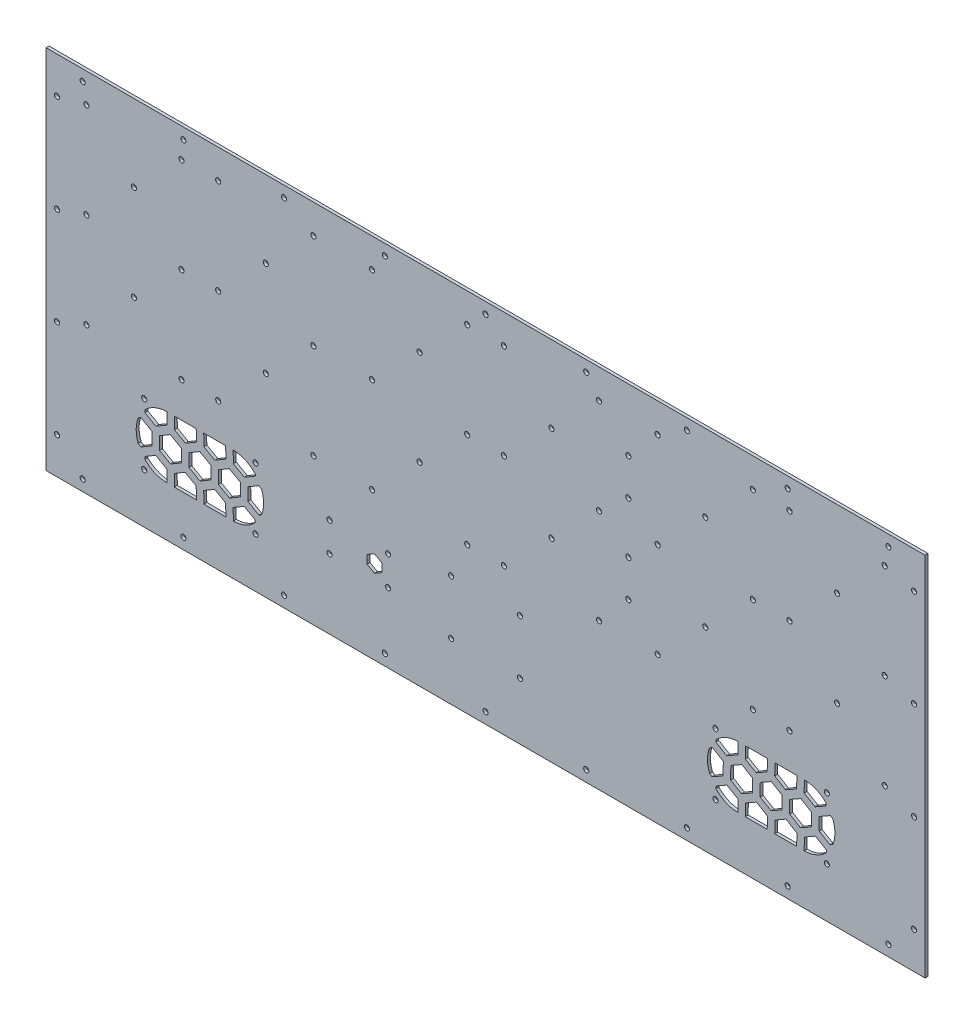
from build123d import *

# Parameters (mm, degrees)
CROQUIS2_W              = 600
CROQUIS2_H              = 250
SALIENTE_EXTRUIR1_DEPTH = 4
CROQUIS4_R              = 1.25
CROQUIS4_W              = 10
CROQUIS4_H              = 15
CORTAR_EXTRUIR4_DEPTH   = 2
CROQUIS5_R              = 1.25
CORTAR_EXTRUIR3_DEPTH   = 5
CROQUIS8_R              = 1.25
CORTAR_EXTRUIR6_DEPTH   = 5
CROQUIS11_R             = 1.25
CORTAR_EXTRUIR9_DEPTH   = 5
CORTAR_EXTRUIR7_DEPTH   = 5
CROQUIS13_R             = 1.25
CORTAR_EXTRUIR10_DEPTH  = 5
CORTAR_EXTRUIR11_DEPTH  = 2
CORTAR_EXTRUIR12_DEPTH  = 3
CROQUIS16_W             = 2
CROQUIS16_H             = 250
CORTAR_EXTRUIR13_DEPTH  = 601
CROQUIS17_R             = 1.75
CORTAR_EXTRUIR14_DEPTH  = 3


with BuildPart() as part:
    # Croquis2 → Saliente-Extruir1 (new body)
    with BuildSketch(Plane.XY):
        Rectangle(CROQUIS2_W, CROQUIS2_H)
    extrude(amount=SALIENTE_EXTRUIR1_DEPTH)

    # Croquis4 → Cortar-Extruir4 (cut)
    with BuildSketch(Plane(origin=(0, 0, 0), x_dir=(-1, 0, 0), z_dir=(0, 0, -1))):
        with Locations((-77.5, -25)):
            Circle(CROQUIS4_R)
        with Locations((-12.5, -25)):
            Circle(CROQUIS4_R)
        with Locations((-12.5, 40)):
            Circle(CROQUIS4_R)
        with Locations((-45, 7.5)):
            Circle(CROQUIS4_R)
        with Locations((-77.5, 40)):
            Circle(CROQUIS4_R)
        with Locations((-45, 72.5)):
            Circle(CROQUIS4_R)
        with Locations((-77.5, 105)):
            Circle(CROQUIS4_R)
        with Locations((-12.5, 105)):
            Circle(CROQUIS4_R)
        with Locations((12.5, -25)):
            Circle(CROQUIS4_R)
        with Locations((77.5, -25)):
            Circle(CROQUIS4_R)
        with Locations((77.5, 40)):
            Circle(CROQUIS4_R)
        with Locations((45, 7.5)):
            Circle(CROQUIS4_R)
        with Locations((12.5, 40)):
            Circle(CROQUIS4_R)
        with Locations((45, 72.5)):
            Circle(CROQUIS4_R)
        with Locations((12.5, 105)):
            Circle(CROQUIS4_R)
        with Locations((77.5, 105)):
            Circle(CROQUIS4_R)
        with Locations((117.5, -25)):
            Circle(CROQUIS4_R)
        with Locations((182.5, -25)):
            Circle(CROQUIS4_R)
        with Locations((182.5, 40)):
            Circle(CROQUIS4_R)
        with Locations((150, 7.5)):
            Circle(CROQUIS4_R)
        with Locations((117.5, 40)):
            Circle(CROQUIS4_R)
        with Locations((150, 72.5)):
            Circle(CROQUIS4_R)
        with Locations((117.5, 105)):
            Circle(CROQUIS4_R)
        with Locations((182.5, 105)):
            Circle(CROQUIS4_R)
        with Locations((-182.5, -25)):
            Circle(CROQUIS4_R)
        with Locations((-117.5, -25)):
            Circle(CROQUIS4_R)
        with Locations((-117.5, 40)):
            Circle(CROQUIS4_R)
        with Locations((-150, 7.5)):
            Circle(CROQUIS4_R)
        with Locations((-182.5, 40)):
            Circle(CROQUIS4_R)
        with Locations((-150, 72.5)):
            Circle(CROQUIS4_R)
        with Locations((-182.5, 105)):
            Circle(CROQUIS4_R)
        with Locations((-117.5, 105)):
            Circle(CROQUIS4_R)
        with Locations((207.5, -25)):
            Circle(CROQUIS4_R)
        with Locations((272.5, -25)):
            Circle(CROQUIS4_R)
        with Locations((272.5, 40)):
            Circle(CROQUIS4_R)
        with Locations((240, 7.5)):
            Circle(CROQUIS4_R)
        with Locations((207.5, 40)):
            Circle(CROQUIS4_R)
        with Locations((240, 72.5)):
            Circle(CROQUIS4_R)
        with Locations((207.5, 105)):
            Circle(CROQUIS4_R)
        with Locations((272.5, 105)):
            Circle(CROQUIS4_R)
        with Locations((-272.5, -25)):
            Circle(CROQUIS4_R)
        with Locations((-207.5, -25)):
            Circle(CROQUIS4_R)
        with Locations((-207.5, 40)):
            Circle(CROQUIS4_R)
        with Locations((-240, 7.5)):
            Circle(CROQUIS4_R)
        with Locations((-272.5, 40)):
            Circle(CROQUIS4_R)
        with Locations((-240, 72.5)):
            Circle(CROQUIS4_R)
        with Locations((-272.5, 105)):
            Circle(CROQUIS4_R)
        with Locations((-207.5, 105)):
            Circle(CROQUIS4_R)
        Polygon((221.999998415, 92.000001585), (213.999998415, 100.000001585), (221.999998415, 108.000001585), (257.999998415, 108.000001585), (265.999998415, 100.000001585), (257.999998415, 92.000001585), align=None)
        Polygon((-262, -8), (-270, -16), (-278, -8), (-278, 28), (-270, 36), (-262, 28), align=None)
        Polygon((-258.000001585, 92.000001585), (-266.000001585, 100.000001585), (-258.000001585, 108.000001585), (-222.000001585, 108.000001585), (-214.000001585, 100.000001585), (-222.000001585, 92.000001585), align=None)
        Polygon((-168.000001585, -12.000001585), (-176.000001585, -20.000001585), (-168.000001585, -28.000001585), (-132.000001585, -28.000001585), (-124.000001585, -20.000001585), (-132.000001585, -12.000001585), align=None)
        Polygon((222, 32), (214, 40), (222, 48), (258, 48), (266, 40), (258, 32), align=None)
        Polygon((-168.000001585, 92.000001585), (-176.000001585, 100.000001585), (-168.000001585, 108.000001585), (-132.000001585, 108.000001585), (-124.000001585, 100.000001585), (-132.000001585, 92.000001585), align=None)
        Polygon((221.999998415, -12.000001585), (213.999998415, -20.000001585), (221.999998415, -28.000001585), (257.999998415, -28.000001585), (265.999998415, -20.000001585), (257.999998415, -12.000001585), align=None)
        Polygon((262, -8), (270, -16), (278, -8), (278, 28), (270, 36), (262, 28), align=None)
        Polygon((218, 88), (210, 96), (202, 88), (202, 52), (210, 44), (218, 52), align=None)
        Polygon((218, -8), (210, -16), (202, -8), (202, 28), (210, 36), (218, 28), align=None)
        Polygon((-128, -8), (-120, -16), (-112, -8), (-112, 28), (-120, 36), (-128, 28), align=None)
        Polygon((-168, 32), (-176, 40), (-168, 48), (-132, 48), (-124, 40), (-132, 32), align=None)
        Polygon((-262, 88), (-270, 96), (-278, 88), (-278, 52), (-270, 44), (-262, 52), align=None)
        Polygon((262, 88), (270, 96), (278, 88), (278, 52), (270, 44), (262, 52), align=None)
        Polygon((-218, 88), (-210, 96), (-202, 88), (-202, 52), (-210, 44), (-218, 52), align=None)
        Polygon((-258, 32), (-266, 40), (-258, 48), (-222, 48), (-214, 40), (-222, 32), align=None)
        Polygon((-218, -8), (-210, -16), (-202, -8), (-202, 28), (-210, 36), (-218, 28), align=None)
        Polygon((-258.000001585, -12.000001585), (-266.000001585, -20.000001585), (-258.000001585, -28.000001585), (-222.000001585, -28.000001585), (-214.000001585, -20.000001585), (-222.000001585, -12.000001585), align=None)
        Polygon((128, 88), (120, 96), (112, 88), (112, 52), (120, 44), (128, 52), align=None)
        Polygon((131.999998415, 92.000001585), (123.999998415, 100.000001585), (131.999998415, 108.000001585), (167.999998415, 108.000001585), (175.999998415, 100.000001585), (167.999998415, 92.000001585), align=None)
        Polygon((128, -8), (120, -16), (112, -8), (112, 28), (120, 36), (128, 28), align=None)
        Polygon((131.999998415, -12.000001585), (123.999998415, -20.000001585), (131.999998415, -28.000001585), (167.999998415, -28.000001585), (175.999998415, -20.000001585), (167.999998415, -12.000001585), align=None)
        Polygon((132, 32), (124, 40), (132, 48), (168, 48), (176, 40), (168, 32), align=None)
        Polygon((172, -8), (180, -16), (188, -8), (188, 28), (180, 36), (172, 28), align=None)
        Polygon((-128, 88), (-120, 96), (-112, 88), (-112, 52), (-120, 44), (-128, 52), align=None)
        Polygon((-172, -8), (-180, -16), (-188, -8), (-188, 28), (-180, 36), (-172, 28), align=None)
        Polygon((-172, 88), (-180, 96), (-188, 88), (-188, 52), (-180, 44), (-172, 52), align=None)
        Polygon((172, 88), (180, 96), (188, 88), (188, 52), (180, 44), (172, 52), align=None)
        Polygon((-67, 88), (-75, 96), (-83, 88), (-83, 52), (-75, 44), (-67, 52), align=None)
        Polygon((-63.000001585, -12.000001585), (-71.000001585, -20.000001585), (-63.000001585, -28.000001585), (-27.000001585, -28.000001585), (-19.000001585, -20.000001585), (-27.000001585, -12.000001585), align=None)
        Polygon((-63, 32), (-71, 40), (-63, 48), (-27, 48), (-19, 40), (-27, 32), align=None)
        Polygon((-23, -8), (-15, -16), (-7, -8), (-7, 28), (-15, 36), (-23, 28), align=None)
        Polygon((23, 88), (15, 96), (7, 88), (7, 52), (15, 44), (23, 52), align=None)
        Polygon((-23, 88), (-15, 96), (-7, 88), (-7, 52), (-15, 44), (-23, 52), align=None)
        Polygon((-63.000001585, 92.000001585), (-71.000001585, 100.000001585), (-63.000001585, 108.000001585), (-27.000001585, 108.000001585), (-19.000001585, 100.000001585), (-27.000001585, 92.000001585), align=None)
        Polygon((67, 88), (75, 96), (83, 88), (83, 52), (75, 44), (67, 52), align=None)
        Polygon((23, -8), (15, -16), (7, -8), (7, 28), (15, 36), (23, 28), align=None)
        Polygon((-67, -8), (-75, -16), (-83, -8), (-83, 28), (-75, 36), (-67, 28), align=None)
        Polygon((26.999998415, 92.000001585), (18.999998415, 100.000001585), (26.999998415, 108.000001585), (62.999998415, 108.000001585), (70.999998415, 100.000001585), (62.999998415, 92.000001585), align=None)
        Polygon((27, 32), (19, 40), (27, 48), (63, 48), (71, 40), (63, 32), align=None)
        Polygon((67, -8), (75, -16), (83, -8), (83, 28), (75, 36), (67, 28), align=None)
        Polygon((26.999998415, -12.000001585), (18.999998415, -20.000001585), (26.999998415, -28.000001585), (62.999998415, -28.000001585), (70.999998415, -20.000001585), (62.999998415, -12.000001585), align=None)
        with Locations((-97.5, 10)):
            Rectangle(CROQUIS4_W, CROQUIS4_H)
        with Locations((-97.5, 70)):
            Rectangle(CROQUIS4_W, CROQUIS4_H)
    extrude(amount=-CORTAR_EXTRUIR4_DEPTH, mode=Mode.SUBTRACT)

    # Croquis5 → Cortar-Extruir3 (cut, through all)
    with BuildSketch(Plane.XY):
        with Locations((-292.5, 100)):
            Circle(CROQUIS5_R)
        with Locations((-292.5, -100)):
            Circle(CROQUIS5_R)
        with Locations((-292.5, 33.333333333)):
            Circle(CROQUIS5_R)
        with Locations((-292.5, -33.333333333)):
            Circle(CROQUIS5_R)
        with Locations((292.5, -33.333333333)):
            Circle(CROQUIS5_R)
        with Locations((292.5, 33.333333333)):
            Circle(CROQUIS5_R)
        with Locations((292.5, -100)):
            Circle(CROQUIS5_R)
        with Locations((292.5, 100)):
            Circle(CROQUIS5_R)
        with Locations((-275, 117.5)):
            Circle(CROQUIS5_R)
        with Locations((-206.25, 117.5)):
            Circle(CROQUIS5_R)
        with Locations((-137.5, 117.5)):
            Circle(CROQUIS5_R)
        with Locations((-68.75, 117.5)):
            Circle(CROQUIS5_R)
        with Locations((68.75, 117.5)):
            Circle(CROQUIS5_R)
        with Locations((137.5, 117.5)):
            Circle(CROQUIS5_R)
        with Locations((206.25, 117.5)):
            Circle(CROQUIS5_R)
        with Locations((275, 117.5)):
            Circle(CROQUIS5_R)
        with Locations((0, 117.5)):
            Circle(CROQUIS5_R)
        with Locations((0, -117.5)):
            Circle(CROQUIS5_R)
        with Locations((275, -117.5)):
            Circle(CROQUIS5_R)
        with Locations((206.25, -117.5)):
            Circle(CROQUIS5_R)
        with Locations((137.5, -117.5)):
            Circle(CROQUIS5_R)
        with Locations((68.75, -117.5)):
            Circle(CROQUIS5_R)
        with Locations((-68.75, -117.5)):
            Circle(CROQUIS5_R)
        with Locations((-137.5, -117.5)):
            Circle(CROQUIS5_R)
        with Locations((-206.25, -117.5)):
            Circle(CROQUIS5_R)
        with Locations((-275, -117.5)):
            Circle(CROQUIS5_R)
        with Locations((-77.5, -25)):
            Circle(CROQUIS5_R)
        with Locations((-12.5, -25)):
            Circle(CROQUIS5_R)
        with Locations((-12.5, 40)):
            Circle(CROQUIS5_R)
        with Locations((-45, 7.5)):
            Circle(CROQUIS5_R)
        with Locations((-77.5, 40)):
            Circle(CROQUIS5_R)
        with Locations((-45, 72.5)):
            Circle(CROQUIS5_R)
        with Locations((-77.5, 105)):
            Circle(CROQUIS5_R)
        with Locations((-12.5, 105)):
            Circle(CROQUIS5_R)
        with Locations((12.5, -25)):
            Circle(CROQUIS5_R)
        with Locations((77.5, -25)):
            Circle(CROQUIS5_R)
        with Locations((77.5, 40)):
            Circle(CROQUIS5_R)
        with Locations((45, 7.5)):
            Circle(CROQUIS5_R)
        with Locations((12.5, 40)):
            Circle(CROQUIS5_R)
        with Locations((45, 72.5)):
            Circle(CROQUIS5_R)
        with Locations((12.5, 105)):
            Circle(CROQUIS5_R)
        with Locations((77.5, 105)):
            Circle(CROQUIS5_R)
        with Locations((117.5, -25)):
            Circle(CROQUIS5_R)
        with Locations((182.5, -25)):
            Circle(CROQUIS5_R)
        with Locations((182.5, 40)):
            Circle(CROQUIS5_R)
        with Locations((150, 7.5)):
            Circle(CROQUIS5_R)
        with Locations((117.5, 40)):
            Circle(CROQUIS5_R)
        with Locations((150, 72.5)):
            Circle(CROQUIS5_R)
        with Locations((117.5, 105)):
            Circle(CROQUIS5_R)
        with Locations((182.5, 105)):
            Circle(CROQUIS5_R)
        with Locations((-182.5, -25)):
            Circle(CROQUIS5_R)
        with Locations((-117.5, -25)):
            Circle(CROQUIS5_R)
        with Locations((-117.5, 40)):
            Circle(CROQUIS5_R)
        with Locations((-150, 7.5)):
            Circle(CROQUIS5_R)
        with Locations((-182.5, 40)):
            Circle(CROQUIS5_R)
        with Locations((-150, 72.5)):
            Circle(CROQUIS5_R)
        with Locations((-182.5, 105)):
            Circle(CROQUIS5_R)
        with Locations((-117.5, 105)):
            Circle(CROQUIS5_R)
        with Locations((207.5, -25)):
            Circle(CROQUIS5_R)
        with Locations((272.5, -25)):
            Circle(CROQUIS5_R)
        with Locations((272.5, 40)):
            Circle(CROQUIS5_R)
        with Locations((240, 7.5)):
            Circle(CROQUIS5_R)
        with Locations((207.5, 40)):
            Circle(CROQUIS5_R)
        with Locations((240, 72.5)):
            Circle(CROQUIS5_R)
        with Locations((207.5, 105)):
            Circle(CROQUIS5_R)
        with Locations((272.5, 105)):
            Circle(CROQUIS5_R)
        with Locations((-272.5, -25)):
            Circle(CROQUIS5_R)
        with Locations((-207.5, -25)):
            Circle(CROQUIS5_R)
        with Locations((-207.5, 40)):
            Circle(CROQUIS5_R)
        with Locations((-240, 7.5)):
            Circle(CROQUIS5_R)
        with Locations((-272.5, 40)):
            Circle(CROQUIS5_R)
        with Locations((-240, 72.5)):
            Circle(CROQUIS5_R)
        with Locations((-272.5, 105)):
            Circle(CROQUIS5_R)
        with Locations((-207.5, 105)):
            Circle(CROQUIS5_R)
        with Locations((97.5, 22.5)):
            Circle(CROQUIS5_R)
        with Locations((97.5, -2.5)):
            Circle(CROQUIS5_R)
        with Locations((97.5, 57.5)):
            Circle(CROQUIS5_R)
        with Locations((97.5, 82.5)):
            Circle(CROQUIS5_R)
    extrude(amount=CORTAR_EXTRUIR3_DEPTH, mode=Mode.SUBTRACT)

    # Croquis8 → Cortar-Extruir6 (cut, through all)
    with BuildSketch(Plane.XY.offset(4)):
        with Locations((-233, -49)):
            Circle(CROQUIS8_R)
        with Locations((-233, -91)):
            Circle(CROQUIS8_R)
        with Locations((-157, -91)):
            Circle(CROQUIS8_R)
        with Locations((-157, -49)):
            Circle(CROQUIS8_R)
        with Locations((157, -49)):
            Circle(CROQUIS8_R)
        with Locations((157, -91)):
            Circle(CROQUIS8_R)
        with Locations((233, -91)):
            Circle(CROQUIS8_R)
        with Locations((233, -49)):
            Circle(CROQUIS8_R)
    extrude(amount=-CORTAR_EXTRUIR6_DEPTH, mode=Mode.SUBTRACT)

    # Croquis11 → Cortar-Extruir9 (cut, through all)
    with BuildSketch(Plane(origin=(0, 0, 0), x_dir=(-1, 0, 0), z_dir=(0, 0, -1))):
        with Locations((-23.5, -49)):
            Circle(CROQUIS11_R)
        with Locations((23.5, -49)):
            Circle(CROQUIS11_R)
        with Locations((23.5, -86)):
            Circle(CROQUIS11_R)
        with Locations((-23.5, -86)):
            Circle(CROQUIS11_R)
    extrude(amount=-CORTAR_EXTRUIR9_DEPTH, mode=Mode.SUBTRACT)

    # Croquis9 → Cortar-Extruir7 (cut, through all)
    with BuildSketch(Plane.XY.offset(4)):
        Polygon((207.660336161, -65.60072068), (215.200047582, -61.340116065), (222.659695125, -65.739395385), (222.579631247, -74.39927932), (215.039919826, -78.659883935), (207.580272283, -74.260604615), align=None)
        with BuildLine():
            Line((232.539914551, -57.026597388), (232.555325078, -55.359761149))
            ThreePointArc((232.555325078, -55.359761149), (225.723977048, -50.677322197), (217.613479558, -49.000306719))
            Line((217.613479558, -49.000306719), (217.540555588, -56.887922683))
            Line((217.540555588, -56.887922683), (225.00020313, -61.287202004))
            Line((225.00020313, -61.287202004), (232.539914551, -57.026597388))
        make_face()
        Polygon((212.419939167, -57.026597388), (212.494148073, -49), (197.49350701, -49), (197.420580203, -56.887922683), (204.880227746, -61.287202004), align=None)
        Polygon((192.299963782, -57.026597388), (192.374172689, -49), (177.373531625, -49), (177.300604818, -56.887922683), (184.760252361, -61.287202004), align=None)
        with BuildLine():
            ThreePointArc((172.254184004, -49.001438522), (164.047678268, -50.77609326), (157.192316823, -55.623789135))
            Line((157.192316823, -55.623789135), (157.180629434, -56.887922683))
            Line((157.180629434, -56.887922683), (164.640276977, -61.287202004))
            Line((164.640276977, -61.287202004), (172.179988398, -57.026597388))
            Line((172.179988398, -57.026597388), (172.254184004, -49.001438522))
        make_face()
        with BuildLine():
            ThreePointArc((152.911967347, -62.42967976), (151.500005641, -70.03262348), (152.935582835, -77.631143545))
            Line((152.935582835, -77.631143545), (154.679968714, -78.659883935))
            Line((154.679968714, -78.659883935), (162.219680135, -74.39927932))
            Line((162.219680135, -74.39927932), (162.299744014, -65.739395385))
            Line((162.299744014, -65.739395385), (154.840096471, -61.340116065))
            Line((154.840096471, -61.340116065), (152.911967347, -62.42967976))
        make_face()
        with BuildLine():
            ThreePointArc((157.24585479, -84.433005747), (164.052101947, -89.225851121), (172.185803255, -90.997649697))
            Line((172.185803255, -90.997649697), (172.260052276, -82.966713452))
            Line((172.260052276, -82.966713452), (164.800404733, -78.567434132))
            Line((164.800404733, -78.567434132), (157.260693312, -82.828038748))
            Line((157.260693312, -82.828038748), (157.24585479, -84.433005747))
        make_face()
        Polygon((167.420368753, -65.60072068), (174.960080174, -61.340116065), (182.419727717, -65.739395385), (182.339663839, -74.39927932), (174.799952418, -78.659883935), (167.340304875, -74.260604615), align=None)
        Polygon((177.305115847, -91), (192.30575691, -91), (192.38002766, -82.966713452), (184.920380118, -78.567434132), (177.380668697, -82.828038748), align=None)
        Polygon((187.540352457, -65.60072068), (195.080063878, -61.340116065), (202.539711421, -65.739395385), (202.459647543, -74.39927932), (194.919936122, -78.659883935), (187.460288579, -74.260604615), align=None)
        Polygon((197.425091231, -91), (212.425732295, -91), (212.500003045, -82.966713452), (205.040355502, -78.567434132), (197.500644081, -82.828038748), align=None)
        with BuildLine():
            Line((217.620619466, -82.828038748), (217.545067063, -90.9999516))
            ThreePointArc((217.545067063, -90.9999516), (225.725328044, -89.322102746), (232.604979759, -84.589002412))
            Line((232.604979759, -84.589002412), (232.61997843, -82.966713452))
            Line((232.61997843, -82.966713452), (225.160330887, -78.567434132))
            Line((225.160330887, -78.567434132), (217.620619466, -82.828038748))
        make_face()
        with BuildLine():
            Line((235.159903529, -78.659883935), (237.087982246, -77.570348724))
            ThreePointArc((237.087982246, -77.570348724), (238.499954959, -69.967375593), (237.064365996, -62.368826278))
            Line((237.064365996, -62.368826278), (235.320031286, -61.340116065))
            Line((235.320031286, -61.340116065), (227.780319865, -65.60072068))
            Line((227.780319865, -65.60072068), (227.700255986, -74.260604615))
            Line((227.700255986, -74.260604615), (235.159903529, -78.659883935))
        make_face()
        Polygon((-212.500003045, -82.966713452), (-212.425732295, -91), (-197.425091231, -91), (-197.500644081, -82.828038748), (-205.040355502, -78.567434132), align=None)
        Polygon((-192.38002766, -82.966713452), (-192.30575691, -91), (-177.305115847, -91), (-177.380668697, -82.828038748), (-184.920380118, -78.567434132), align=None)
        with BuildLine():
            ThreePointArc((-172.185803255, -90.997649697), (-164.052101947, -89.225851121), (-157.24585479, -84.433005747))
            Line((-157.24585479, -84.433005747), (-157.260693312, -82.828038748))
            Line((-157.260693312, -82.828038748), (-164.800404733, -78.567434132))
            Line((-164.800404733, -78.567434132), (-172.260052276, -82.966713452))
            Line((-172.260052276, -82.966713452), (-172.185803255, -90.997649697))
        make_face()
        with BuildLine():
            ThreePointArc((-152.935582835, -77.631143545), (-151.500005641, -70.03262348), (-152.911967347, -62.42967976))
            Line((-152.911967347, -62.42967976), (-154.840096471, -61.340116065))
            Line((-154.840096471, -61.340116065), (-162.299744014, -65.739395385))
            Line((-162.299744014, -65.739395385), (-162.219680135, -74.39927932))
            Line((-162.219680135, -74.39927932), (-154.679968714, -78.659883935))
            Line((-154.679968714, -78.659883935), (-152.935582835, -77.631143545))
        make_face()
        Polygon((-174.799952418, -78.659883935), (-167.340304875, -74.260604615), (-167.420368753, -65.60072068), (-174.960080174, -61.340116065), (-182.419727717, -65.739395385), (-182.339663839, -74.39927932), align=None)
        Polygon((-194.919936122, -78.659883935), (-187.460288579, -74.260604615), (-187.540352457, -65.60072068), (-195.080063878, -61.340116065), (-202.539711421, -65.739395385), (-202.459647543, -74.39927932), align=None)
        Polygon((-215.039919826, -78.659883935), (-207.580272283, -74.260604615), (-207.660336161, -65.60072068), (-215.200047582, -61.340116065), (-222.659695125, -65.739395385), (-222.579631247, -74.39927932), align=None)
        with BuildLine():
            Line((-232.61997843, -82.966713452), (-232.604979759, -84.589002412))
            ThreePointArc((-232.604979759, -84.589002412), (-225.725328044, -89.322102746), (-217.545067063, -90.9999516))
            Line((-217.545067063, -90.9999516), (-217.620619466, -82.828038748))
            Line((-217.620619466, -82.828038748), (-225.160330887, -78.567434132))
            Line((-225.160330887, -78.567434132), (-232.61997843, -82.966713452))
        make_face()
        with BuildLine():
            Line((-235.320031286, -61.340116065), (-237.064365996, -62.368826278))
            ThreePointArc((-237.064365996, -62.368826278), (-238.499954959, -69.967375593), (-237.087982246, -77.570348724))
            Line((-237.087982246, -77.570348724), (-235.159903529, -78.659883935))
            Line((-235.159903529, -78.659883935), (-227.700255986, -74.260604615))
            Line((-227.700255986, -74.260604615), (-227.780319865, -65.60072068))
            Line((-227.780319865, -65.60072068), (-235.320031286, -61.340116065))
        make_face()
        with BuildLine():
            Line((-217.540555588, -56.887922683), (-217.613479558, -49.000306719))
            ThreePointArc((-217.613479558, -49.000306719), (-225.723977048, -50.677322197), (-232.555325078, -55.359761149))
            Line((-232.555325078, -55.359761149), (-232.539914551, -57.026597388))
            Line((-232.539914551, -57.026597388), (-225.00020313, -61.287202004))
            Line((-225.00020313, -61.287202004), (-217.540555588, -56.887922683))
        make_face()
        Polygon((-197.49350701, -49), (-212.494148073, -49), (-212.419939167, -57.026597388), (-204.880227746, -61.287202004), (-197.420580203, -56.887922683), align=None)
        Polygon((-177.373531625, -49), (-192.374172689, -49), (-192.299963782, -57.026597388), (-184.760252361, -61.287202004), (-177.300604818, -56.887922683), align=None)
        with BuildLine():
            ThreePointArc((-157.192316823, -55.623789135), (-164.047678268, -50.77609326), (-172.254184004, -49.001438522))
            Line((-172.254184004, -49.001438522), (-172.179988398, -57.026597388))
            Line((-172.179988398, -57.026597388), (-164.640276977, -61.287202004))
            Line((-164.640276977, -61.287202004), (-157.180629434, -56.887922683))
            Line((-157.180629434, -56.887922683), (-157.192316823, -55.623789135))
        make_face()
    extrude(amount=-CORTAR_EXTRUIR7_DEPTH, mode=Mode.SUBTRACT)

    # Croquis13 → Cortar-Extruir10 (cut, through all)
    with BuildSketch(Plane(origin=(0, 0, 0), x_dir=(-1, 0, 0), z_dir=(0, 0, -1))):
        with Locations((66.5, -57.5)):
            Circle(CROQUIS13_R)
        with Locations((66.5, -77.5)):
            Circle(CROQUIS13_R)
        with Locations((106.5, -77.5)):
            Circle(CROQUIS13_R)
        with Locations((106.5, -57.5)):
            Circle(CROQUIS13_R)
    extrude(amount=-CORTAR_EXTRUIR10_DEPTH, mode=Mode.SUBTRACT)

    # Croquis14 → Cortar-Extruir11 (cut)
    with BuildSketch(Plane(origin=(0, 0, 0), x_dir=(-1, 0, 0), z_dir=(0, 0, -1))):
        Polygon((68.85, -76.5), (68.85, -58.5), (83.293122568, -58.5), (83.293122568, -53.5), (83.293122568, -38.5), (98.293122568, -38.5), (98.293122568, -53.5), (98.293122568, -63.5), (100.024999998, -63.5), (111.793122568, -63.5), (111.793122568, -71.5), (98.293122568, -71.5), (98.293122568, -76.5), align=None)
    extrude(amount=-CORTAR_EXTRUIR11_DEPTH, mode=Mode.SUBTRACT)

    # Croquis15 → Cortar-Extruir12 (cut, through all)
    with BuildSketch(Plane(origin=(0, 0, 2), x_dir=(-1, 0, 0), z_dir=(0, 0, -1))):
        Polygon((75.776689089, -62.093987059), (70.776689089, -64.980738405), (70.776689089, -70.754241097), (75.776689089, -73.640992443), (80.776689089, -70.754241097), (80.776689089, -64.980738405), align=None)
    extrude(amount=-CORTAR_EXTRUIR12_DEPTH, mode=Mode.SUBTRACT)

    # Croquis16 → Cortar-Extruir13 (cut, through all)
    with BuildSketch(Plane.ZY.offset(300)):
        with Locations((1, 0)):
            Rectangle(CROQUIS16_W, CROQUIS16_H)
    extrude(amount=-CORTAR_EXTRUIR13_DEPTH, mode=Mode.SUBTRACT)

    # Croquis17 → Cortar-Extruir14 (cut, through all)
    with BuildSketch(Plane.XY.offset(4)):
        with Locations((-292.5, 100)):
            Circle(CROQUIS17_R)
        with Locations((-275, 117.5)):
            Circle(CROQUIS17_R)
        with Locations((-272.5, 105)):
            Circle(CROQUIS17_R)
        with Locations((-240, 72.5)):
            Circle(CROQUIS17_R)
        with Locations((-272.5, 40)):
            Circle(CROQUIS17_R)
        with Locations((-292.5, 33.333333333)):
            Circle(CROQUIS17_R)
        with Locations((-272.5, -25)):
            Circle(CROQUIS17_R)
        with Locations((-292.5, -33.333333333)):
            Circle(CROQUIS17_R)
        with Locations((-292.5, -100)):
            Circle(CROQUIS17_R)
        with Locations((-275, -117.5)):
            Circle(CROQUIS17_R)
        with Locations((-206.25, -117.5)):
            Circle(CROQUIS17_R)
        with Locations((-137.5, -117.5)):
            Circle(CROQUIS17_R)
        with Locations((-68.75, -117.5)):
            Circle(CROQUIS17_R)
        with Locations((0, -117.5)):
            Circle(CROQUIS17_R)
        with Locations((68.75, -117.5)):
            Circle(CROQUIS17_R)
        with Locations((137.5, -117.5)):
            Circle(CROQUIS17_R)
        with Locations((206.25, -117.5)):
            Circle(CROQUIS17_R)
        with Locations((275, -117.5)):
            Circle(CROQUIS17_R)
        with Locations((292.5, -100)):
            Circle(CROQUIS17_R)
        with Locations((233, -91)):
            Circle(CROQUIS17_R)
        with Locations((157, -91)):
            Circle(CROQUIS17_R)
        with Locations((157, -49)):
            Circle(CROQUIS17_R)
        with Locations((233, -49)):
            Circle(CROQUIS17_R)
        with Locations((-106.5, -77.5)):
            Circle(CROQUIS17_R)
        with Locations((-106.5, -57.5)):
            Circle(CROQUIS17_R)
        with Locations((-66.5, -57.5)):
            Circle(CROQUIS17_R)
        with Locations((-66.5, -77.5)):
            Circle(CROQUIS17_R)
        with Locations((-157, -91)):
            Circle(CROQUIS17_R)
        with Locations((-233, -91)):
            Circle(CROQUIS17_R)
        with Locations((-233, -49)):
            Circle(CROQUIS17_R)
        with Locations((-157, -49)):
            Circle(CROQUIS17_R)
        with Locations((-182.5, -25)):
            Circle(CROQUIS17_R)
        with Locations((-207.5, -25)):
            Circle(CROQUIS17_R)
        with Locations((-240, 7.5)):
            Circle(CROQUIS17_R)
        with Locations((-207.5, 40)):
            Circle(CROQUIS17_R)
        with Locations((-182.5, 40)):
            Circle(CROQUIS17_R)
        with Locations((-150, 7.5)):
            Circle(CROQUIS17_R)
        with Locations((-117.5, -25)):
            Circle(CROQUIS17_R)
        with Locations((-77.5, -25)):
            Circle(CROQUIS17_R)
        with Locations((-77.5, 40)):
            Circle(CROQUIS17_R)
        with Locations((-117.5, 40)):
            Circle(CROQUIS17_R)
        with Locations((-150, 72.5)):
            Circle(CROQUIS17_R)
        with Locations((-182.5, 105)):
            Circle(CROQUIS17_R)
        with Locations((-207.5, 105)):
            Circle(CROQUIS17_R)
        with Locations((-206.25, 117.5)):
            Circle(CROQUIS17_R)
        with Locations((-137.5, 117.5)):
            Circle(CROQUIS17_R)
        with Locations((-117.5, 105)):
            Circle(CROQUIS17_R)
        with Locations((-77.5, 105)):
            Circle(CROQUIS17_R)
        with Locations((-68.75, 117.5)):
            Circle(CROQUIS17_R)
        with Locations((0, 117.5)):
            Circle(CROQUIS17_R)
        with Locations((-12.5, 105)):
            Circle(CROQUIS17_R)
        with Locations((12.5, 105)):
            Circle(CROQUIS17_R)
        with Locations((-45, 72.5)):
            Circle(CROQUIS17_R)
        with Locations((45, 72.5)):
            Circle(CROQUIS17_R)
        with Locations((-12.5, 40)):
            Circle(CROQUIS17_R)
        with Locations((-45, 7.5)):
            Circle(CROQUIS17_R)
        with Locations((-23.5, -49)):
            Circle(CROQUIS17_R)
        with Locations((-23.5, -86)):
            Circle(CROQUIS17_R)
        with Locations((23.5, -86)):
            Circle(CROQUIS17_R)
        with Locations((23.5, -49)):
            Circle(CROQUIS17_R)
        with Locations((12.5, -25)):
            Circle(CROQUIS17_R)
        with Locations((-12.5, -25)):
            Circle(CROQUIS17_R)
        with Locations((45, 7.5)):
            Circle(CROQUIS17_R)
        with Locations((12.5, 40)):
            Circle(CROQUIS17_R)
        with Locations((77.5, 40)):
            Circle(CROQUIS17_R)
        with Locations((97.5, 22.5)):
            Circle(CROQUIS17_R)
        with Locations((117.5, 40)):
            Circle(CROQUIS17_R)
        with Locations((97.5, 57.5)):
            Circle(CROQUIS17_R)
        with Locations((97.5, 82.5)):
            Circle(CROQUIS17_R)
        with Locations((77.5, 105)):
            Circle(CROQUIS17_R)
        with Locations((68.75, 117.5)):
            Circle(CROQUIS17_R)
        with Locations((137.5, 117.5)):
            Circle(CROQUIS17_R)
        with Locations((117.5, 105)):
            Circle(CROQUIS17_R)
        with Locations((150, 72.5)):
            Circle(CROQUIS17_R)
        with Locations((117.5, -25)):
            Circle(CROQUIS17_R)
        with Locations((97.5, -2.5)):
            Circle(CROQUIS17_R)
        with Locations((77.5, -25)):
            Circle(CROQUIS17_R)
        with Locations((182.5, -25)):
            Circle(CROQUIS17_R)
        with Locations((207.5, -25)):
            Circle(CROQUIS17_R)
        with Locations((150, 7.5)):
            Circle(CROQUIS17_R)
        with Locations((182.5, 40)):
            Circle(CROQUIS17_R)
        with Locations((207.5, 40)):
            Circle(CROQUIS17_R)
        with Locations((240, 7.5)):
            Circle(CROQUIS17_R)
        with Locations((240, 72.5)):
            Circle(CROQUIS17_R)
        with Locations((207.5, 105)):
            Circle(CROQUIS17_R)
        with Locations((182.5, 105)):
            Circle(CROQUIS17_R)
        with Locations((206.25, 117.5)):
            Circle(CROQUIS17_R)
        with Locations((275, 117.5)):
            Circle(CROQUIS17_R)
        with Locations((272.5, 105)):
            Circle(CROQUIS17_R)
        with Locations((292.5, 100)):
            Circle(CROQUIS17_R)
        with Locations((272.5, 40)):
            Circle(CROQUIS17_R)
        with Locations((292.5, 33.333333333)):
            Circle(CROQUIS17_R)
        with Locations((272.5, -25)):
            Circle(CROQUIS17_R)
        with Locations((292.5, -33.333333333)):
            Circle(CROQUIS17_R)
    extrude(amount=-CORTAR_EXTRUIR14_DEPTH, mode=Mode.SUBTRACT)


solid = part.part
